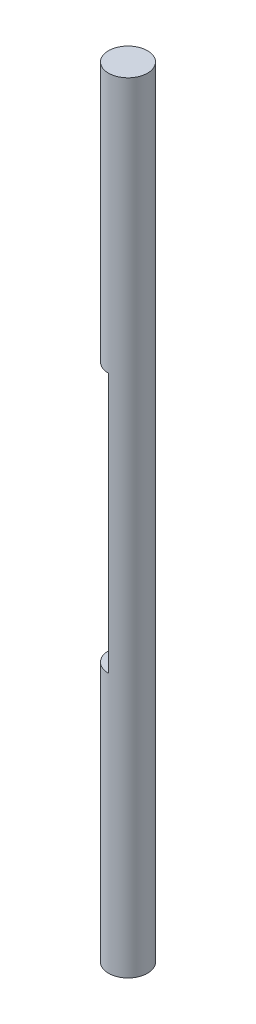
from build123d import *

# Parameters (mm, degrees)
SKETCH_1_R          = 1.5
EXTRUDE_1_DEPTH     = 60
SKETCH_2_W          = 3.094780934
SKETCH_2_H          = 20
CUT_EXTRUDE_1_DEPTH = 40


with BuildPart() as part:
    # 草图1 → 凸台-拉伸1 (new body)
    with BuildSketch(Plane(origin=(0, 0, 0), x_dir=(1, 0, 0), z_dir=(0, 1, 0))):
        Circle(SKETCH_1_R)
    extrude(amount=EXTRUDE_1_DEPTH)

    # 草图2 → 切除-拉伸1 (cut)
    with BuildSketch(Plane(origin=(0, 0, 0), x_dir=(0, 0, -1), z_dir=(1, 0, 0))):
        with Locations((1.547390467, 30)):
            Rectangle(SKETCH_2_W, SKETCH_2_H)
        with Locations((-1.547390467, 30)):
            Rectangle(SKETCH_2_W, SKETCH_2_H)
    extrude(amount=-CUT_EXTRUDE_1_DEPTH, mode=Mode.SUBTRACT)


solid = part.part
